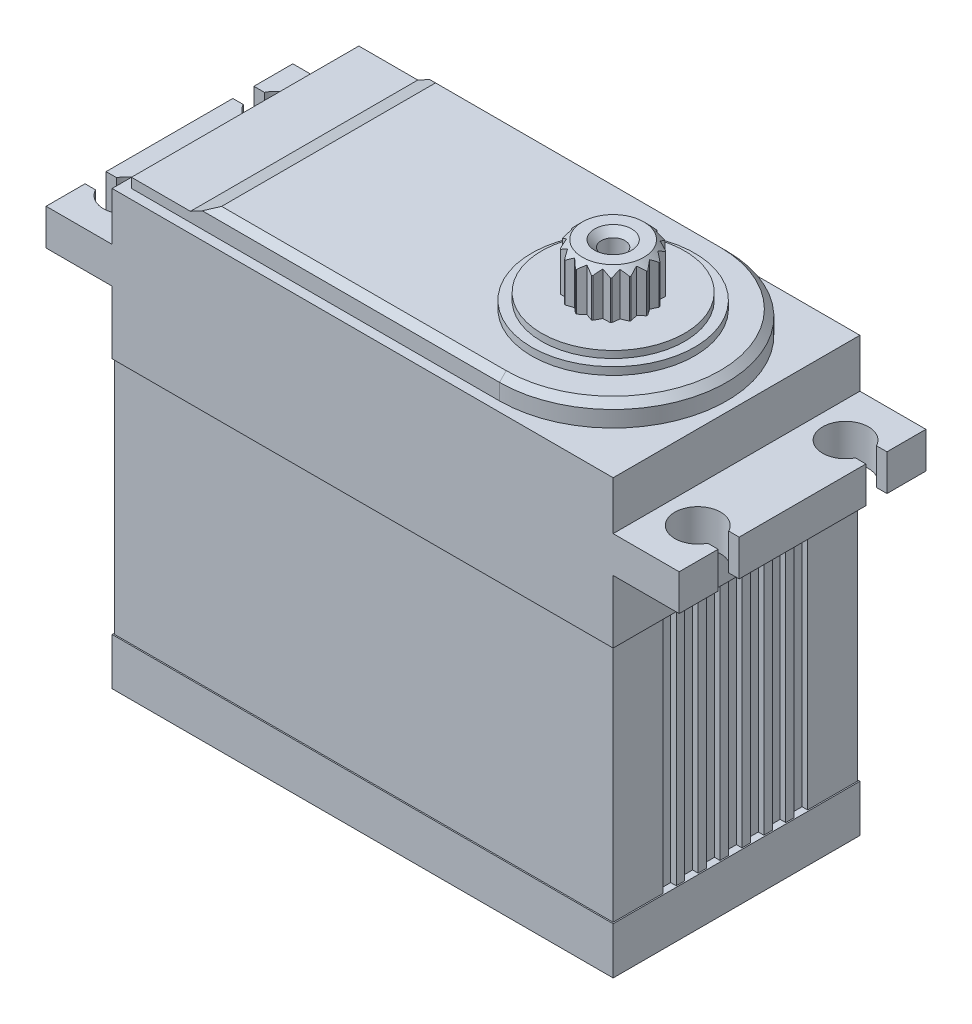
from build123d import *

# Parameters (mm, degrees)
SALIENTE_EXTRUIR1_DEPTH = 29.3
CROQUIS2_W              = 85.211346073
CROQUIS2_H              = 50.160748779
CORTAR_EXTRUIR1_DEPTH   = 28.35
CORTAR_EXTRUIR2_REACH   = 47.7
SALIENTE_EXTRUIR2_DEPTH = 1.15
SALIENTE_EXTRUIR3_DEPTH = 1.56
CHAFL_N1_SIZE           = 0.8
CORTAR_EXTRUIR3_DEPTH   = 30.3
CROQUIS7_R              = 9.68
SALIENTE_EXTRUIR4_DEPTH = 0.9
CROQUIS8_R              = 8.49
SALIENTE_EXTRUIR5_DEPTH = 0.83
CROQUIS9_R              = 4.445
CROQUIS9_R_2            = 1.4
SALIENTE_EXTRUIR6_DEPTH = 5.4
CHAFL_N2_SIZE           = 0.8
CORTAR_EXTRUIR4_DEPTH   = 5.4
MATRIZC1_COUNT          = 17


with BuildPart() as part:
    # Croquis1 → Saliente-Extruir1 (new body)
    with BuildSketch(Plane.XY):
        Polygon((0, 0), (59.5, 0), (59.5, 5.58), (59.355, 5.58), (59.355, 33.93), (59.5, 33.93), (59.5, 41.4), (67.34, 41.4), (67.34, 45.7), (59.5, 45.7), (59.5, 51.45), (0, 51.45), (0, 45.7), (-7.84, 45.7), (-7.84, 41.4), (0, 41.4), (0, 33.93), (0.145, 33.93), (0.145, 5.58), (0, 5.58), align=None)
    extrude(amount=SALIENTE_EXTRUIR1_DEPTH)

    # Croquis2 → Cortar-Extruir1 (cut)
    with BuildSketch(Plane(origin=(0, 5.58, 0), x_dir=(1, 0, 0), z_dir=(0, 1, 0))):
        with Locations((30.740829606, -17.065147164)):
            Rectangle(CROQUIS2_W, CROQUIS2_H)
        Polygon((0.155, -0.15), (59.345, -0.15), (59.345, -6.05), (58.685, -6.05), (58.685, -7.65), (59.345, -7.65), (59.345, -8.65), (58.685, -8.65), (58.685, -10.25), (59.345, -10.25), (59.345, -11.25), (58.685, -11.25), (58.685, -12.85), (59.345, -12.85), (59.345, -13.85), (58.685, -13.85), (58.685, -15.45), (59.345, -15.45), (59.345, -16.45), (58.685, -16.45), (58.685, -18.05), (59.345, -18.05), (59.345, -19.05), (58.685, -19.05), (58.685, -20.65), (59.345, -20.65), (59.345, -21.65), (58.685, -21.65), (58.685, -23.25), (59.345, -23.25), (59.345, -29.15), (0.155, -29.15), (0.155, -23.25), (0.815, -23.25), (0.815, -21.65), (0.155, -21.65), (0.155, -20.65), (0.815, -20.65), (0.815, -19.05), (0.155, -19.05), (0.155, -18.05), (0.815, -18.05), (0.815, -16.45), (0.155, -16.45), (0.155, -15.45), (0.815, -15.45), (0.815, -13.85), (0.155, -13.85), (0.155, -12.85), (0.815, -12.85), (0.815, -11.25), (0.155, -11.25), (0.155, -10.25), (0.815, -10.25), (0.815, -8.65), (0.155, -8.65), (0.155, -7.65), (0.815, -7.65), (0.815, -6.05), (0.155, -6.05), align=None, mode=Mode.SUBTRACT)
    extrude(amount=CORTAR_EXTRUIR1_DEPTH, mode=Mode.SUBTRACT)

    # Croquis3 → Cortar-Extruir2 (cut, up to next)
    with BuildSketch(Plane(origin=(0, 45.7, 0), x_dir=(1, 0, 0), z_dir=(0, 1, 0)), mode=Mode.PRIVATE) as cortar_extruir2_sk1:
        with BuildLine():
            Line((-8.62807943, -4.625), (-6.596389064, -4.625))
            ThreePointArc((-6.596389064, -4.625), (-1.45, -5.875), (-6.596389064, -7.125))
            Line((-6.596389064, -7.125), (-8.62807943, -7.125))
            Line((-8.62807943, -7.125), (-8.62807943, -4.625))
        make_face()
    cortar_extruir2_tool1 = extrude(cortar_extruir2_sk1.sketch, amount=-CORTAR_EXTRUIR2_REACH, mode=Mode.PRIVATE) & part.part
    add(cortar_extruir2_tool1.solids().sort_by_distance((-4.754174, 45.7, 5.875))[0], mode=Mode.SUBTRACT)
    # Croquis3 → Cortar-Extruir2 (cut, up to next)
    with BuildSketch(Plane(origin=(0, 45.7, 0), x_dir=(1, 0, 0), z_dir=(0, 1, 0)), mode=Mode.PRIVATE) as cortar_extruir2_sk2:
        with BuildLine():
            Line((68.12807943, -7.125), (66.096389064, -7.125))
            ThreePointArc((66.096389064, -7.125), (60.95, -5.875), (66.096389064, -4.625))
            Line((66.096389064, -4.625), (68.12807943, -4.625))
            Line((68.12807943, -4.625), (68.12807943, -7.125))
        make_face()
    cortar_extruir2_tool2 = extrude(cortar_extruir2_sk2.sketch, amount=-CORTAR_EXTRUIR2_REACH, mode=Mode.PRIVATE) & part.part
    add(cortar_extruir2_tool2.solids().sort_by_distance((64.254174, 45.7, 5.875))[0], mode=Mode.SUBTRACT)
    # Croquis3 → Cortar-Extruir2 (cut, up to next)
    with BuildSketch(Plane(origin=(0, 45.7, 0), x_dir=(1, 0, 0), z_dir=(0, 1, 0)), mode=Mode.PRIVATE) as cortar_extruir2_sk3:
        with BuildLine():
            Line((68.12807943, -24.675), (66.096389064, -24.675))
            ThreePointArc((66.096389064, -24.675), (60.95, -23.425), (66.096389064, -22.175))
            Line((66.096389064, -22.175), (68.12807943, -22.175))
            Line((68.12807943, -22.175), (68.12807943, -24.675))
        make_face()
    cortar_extruir2_tool3 = extrude(cortar_extruir2_sk3.sketch, amount=-CORTAR_EXTRUIR2_REACH, mode=Mode.PRIVATE) & part.part
    add(cortar_extruir2_tool3.solids().sort_by_distance((64.254174, 45.7, 23.425))[0], mode=Mode.SUBTRACT)
    # Croquis3 → Cortar-Extruir2 (cut, up to next)
    with BuildSketch(Plane(origin=(0, 45.7, 0), x_dir=(1, 0, 0), z_dir=(0, 1, 0)), mode=Mode.PRIVATE) as cortar_extruir2_sk4:
        with BuildLine():
            Line((-8.62807943, -22.175), (-6.596389064, -22.175))
            ThreePointArc((-6.596389064, -22.175), (-1.45, -23.425), (-6.596389064, -24.675))
            Line((-6.596389064, -24.675), (-8.62807943, -24.675))
            Line((-8.62807943, -24.675), (-8.62807943, -22.175))
        make_face()
    cortar_extruir2_tool4 = extrude(cortar_extruir2_sk4.sketch, amount=-CORTAR_EXTRUIR2_REACH, mode=Mode.PRIVATE) & part.part
    add(cortar_extruir2_tool4.solids().sort_by_distance((-4.754174, 45.7, 23.425))[0], mode=Mode.SUBTRACT)

    # Croquis4 → Saliente-Extruir2 (add)
    with BuildSketch(Plane(origin=(0, 51.45, 0), x_dir=(1, 0, 0), z_dir=(0, 1, 0))):
        with BuildLine():
            Line((1.15, -1.15), (44.85, -1.15))
            ThreePointArc((44.85, -1.15), (58.35, -14.65), (44.85, -28.15))
            Line((44.85, -28.15), (1.15, -28.15))
            Line((1.15, -28.15), (1.15, -1.15))
        make_face()
    extrude(amount=SALIENTE_EXTRUIR2_DEPTH)

    # Croquis5 → Saliente-Extruir3 (add)
    with BuildSketch(Plane(origin=(0, 52.6, 0), x_dir=(1, 0, 0), z_dir=(0, 1, 0))):
        with BuildLine():
            Line((8.15, -1.15), (44.85, -1.15))
            ThreePointArc((44.85, -1.15), (58.35, -14.65), (44.85, -28.15))
            Line((44.85, -28.15), (8.15, -28.15))
            Line((8.15, -28.15), (8.15, -1.15))
        make_face()
    extrude(amount=SALIENTE_EXTRUIR3_DEPTH)

    # Chaflán1
    chafl_n1_edges = [part.edges().sort_by_distance(p)[0] for p in [
        (26.5, 54.16, 1.15),
        (58.35, 54.16, 14.65),
        (26.5, 54.16, 28.15),
        (8.15, 54.16, 14.65),
    ]]
    chamfer(chafl_n1_edges, length=CHAFL_N1_SIZE)

    # Croquis6 → Cortar-Extruir3 (cut, through all)
    with BuildSketch(Plane.XY.offset(29.3)):
        Polygon((-14.418501218, 52.6), (8.15, 52.6), (21.570974014, 59.807560118), align=None)
    extrude(amount=-CORTAR_EXTRUIR3_DEPTH, mode=Mode.SUBTRACT)

    # Croquis7 → Saliente-Extruir4 (add)
    with BuildSketch(Plane(origin=(0, 54.16, 0), x_dir=(1, 0, 0), z_dir=(0, 1, 0))):
        with Locations((44.85, -14.65)):
            Circle(CROQUIS7_R)
    extrude(amount=SALIENTE_EXTRUIR4_DEPTH)

    # Croquis8 → Saliente-Extruir5 (add)
    with BuildSketch(Plane(origin=(0, 55.06, 0), x_dir=(1, 0, 0), z_dir=(0, 1, 0))):
        with Locations((44.85, -14.65)):
            Circle(CROQUIS8_R)
    extrude(amount=SALIENTE_EXTRUIR5_DEPTH)

    # Croquis9 → Saliente-Extruir6 (add)
    with BuildSketch(Plane(origin=(0, 55.89, 0), x_dir=(1, 0, 0), z_dir=(0, 1, 0))):
        with Locations((44.85, -14.65)):
            Circle(CROQUIS9_R)
        with Locations((44.85, -14.65)):
            Circle(CROQUIS9_R_2, mode=Mode.SUBTRACT)
    extrude(amount=SALIENTE_EXTRUIR6_DEPTH)

    # Chaflán2
    chafl_n2_edges = [part.edges().sort_by_distance(p)[0] for p in [
        (40.405, 61.29, 14.65),
        (43.45, 61.29, 14.65),
    ]]
    chamfer(chafl_n2_edges, length=CHAFL_N2_SIZE)

    # Croquis10 → Cortar-Extruir4 (cut)
    with BuildSketch(Plane(origin=(0, 61.29, 0), x_dir=(1, 0, 0), z_dir=(0, 1, 0))):
        Polygon((37.454169613, -6.456059857), (44.813549818, -10.705), (52.172930023, -6.456059857), align=None)
    cortar_extruir4 = extrude(amount=-CORTAR_EXTRUIR4_DEPTH, mode=Mode.SUBTRACT)

    # MatrizC1: Cortar-Extruir4 ×17 about axis
    matrizc1_axis = Axis((44.85, 0, 14.65), (0, 1, 0))
    for i in range(1, MATRIZC1_COUNT):
        add(cortar_extruir4.rotate(matrizc1_axis, i * 360 / MATRIZC1_COUNT), mode=Mode.SUBTRACT)


solid = part.part
